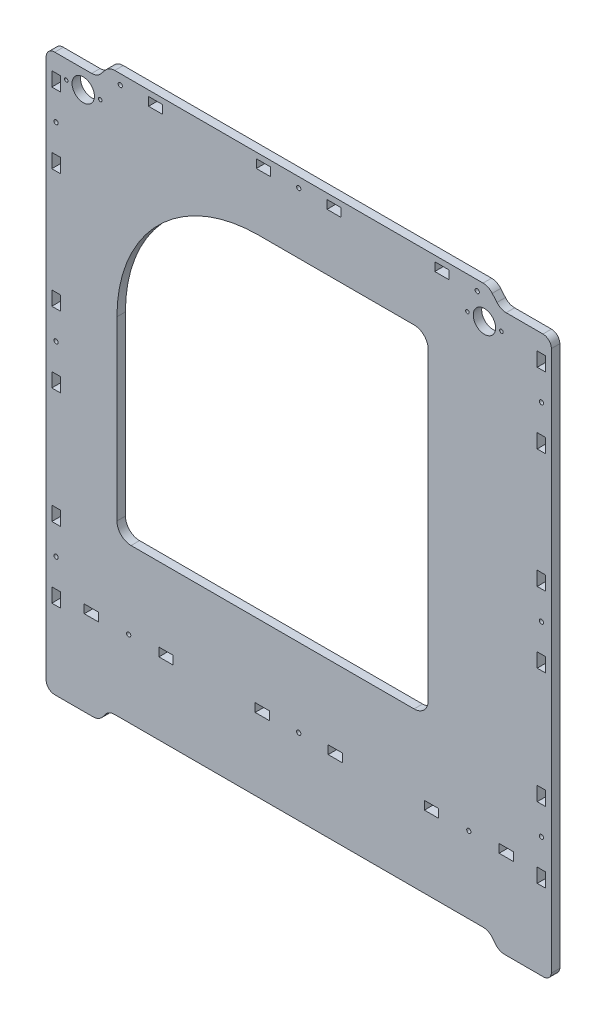
from build123d import *

# Parameters (mm, degrees)
SKETCH_1_R      = 1.5
SKETCH_1_R_2    = 7.9
SKETCH_1_R_3    = 1.25
SKETCH_1_W      = 6
SKETCH_1_H      = 10
SKETCH_1_W_2    = 10
SKETCH_1_H_2    = 6
EXTRUDE_1_DEPTH = 6


with BuildPart() as part:
    # Эскиз1 → Бобышка-Вытянуть1 (new body)
    with BuildSketch(Plane.XY):
        with BuildLine():
            Line((146.861398458, 191.532325026), (172.897783364, 191.532325026))
            ThreePointArc((172.897783364, 191.532325026), (177.076317747, 189.745999648), (178.804179186, 185.542952802))
            Line((178.804179186, 185.542952802), (178.804179186, -196.675834418))
            ThreePointArc((178.804179186, -196.675834418), (176.892140189, -200.429470569), (172.897783364, -201.767674974))
            Line((172.897783364, -201.767674974), (145.861398458, -201.767674974))
            ThreePointArc((145.861398458, -201.767674974), (142.269143233, -200.971291164), (139.350020692, -198.731369657))
            Line((139.350020692, -198.731369657), (137.054194639, -195.711716561))
            ThreePointArc((137.054194639, -195.711716561), (134.135072097, -193.471795054), (130.542816872, -192.675411244))
            Line((130.542816872, -192.675411244), (-129.747250144, -192.675411244))
            ThreePointArc((-129.747250144, -192.675411244), (-133.339505369, -193.471795054), (-136.258627911, -195.711716561))
            Line((-136.258627911, -195.711716561), (-138.554453964, -198.731369657))
            ThreePointArc((-138.554453964, -198.731369657), (-141.473576506, -200.971291164), (-145.06583173, -201.767674974))
            Line((-145.06583173, -201.767674974), (-172.102216636, -201.767674974))
            ThreePointArc((-172.102216636, -201.767674974), (-176.405497525, -200.043755719), (-178.195820814, -195.767674974))
            Line((-178.195820814, -195.767674974), (-178.195820814, 185.542952802))
            ThreePointArc((-178.195820814, 185.542952802), (-176.401714686, 189.812135315), (-172.102216636, 191.532325026))
            Line((-172.102216636, 191.532325026), (-146.06583173, 191.532325026))
            ThreePointArc((-146.06583173, 191.532325026), (-142.473576506, 192.328708836), (-139.554453964, 194.568630343))
            Line((-139.554453964, 194.568630343), (-136.258627911, 198.496442883))
            ThreePointArc((-136.258627911, 198.496442883), (-133.339449219, 200.73613298), (-129.747250144, 201.532325026))
            Line((-129.747250144, 201.532325026), (130.542816872, 201.532325026))
            ThreePointArc((130.542816872, 201.532325026), (134.135072097, 200.735941215), (137.054194639, 198.496019708))
            Line((137.054194639, 198.496019708), (140.350020692, 194.568207169))
            ThreePointArc((140.350020692, 194.568207169), (143.269199383, 192.328517071), (146.861398458, 191.532325026))
        make_face()
        with Locations((120.494179186, -138.767674974)):
            Circle(SKETCH_1_R, mode=Mode.SUBTRACT)
        with Locations((0.304179186, -138.767674974)):
            Circle(SKETCH_1_R, mode=Mode.SUBTRACT)
        with Locations((-119.885820814, -138.767674974)):
            Circle(SKETCH_1_R, mode=Mode.SUBTRACT)
        with Locations((-171.195820814, -116.737674974)):
            Circle(SKETCH_1_R, mode=Mode.SUBTRACT)
        with Locations((-171.195820814, 14.972325026)):
            Circle(SKETCH_1_R, mode=Mode.SUBTRACT)
        with Locations((171.804179186, 149.132325026)):
            Circle(SKETCH_1_R, mode=Mode.SUBTRACT)
        with Locations((126.444179186, 194.532325026)):
            Circle(SKETCH_1_R, mode=Mode.SUBTRACT)
        with Locations((-151.995820814, 178.532325026)):
            Circle(SKETCH_1_R_2, mode=Mode.SUBTRACT)
        with Locations((171.804179186, -116.737674974)):
            Circle(SKETCH_1_R, mode=Mode.SUBTRACT)
        with Locations((171.804179186, 14.972325026)):
            Circle(SKETCH_1_R, mode=Mode.SUBTRACT)
        with Locations((-171.195820814, 149.132325026)):
            Circle(SKETCH_1_R, mode=Mode.SUBTRACT)
        with Locations((-125.835820814, 194.532325026)):
            Circle(SKETCH_1_R, mode=Mode.SUBTRACT)
        with Locations((0.304179186, 194.54440539)):
            Circle(SKETCH_1_R, mode=Mode.SUBTRACT)
        with Locations((131.504179186, 178.532325026)):
            Circle(SKETCH_1_R_2, mode=Mode.SUBTRACT)
        with Locations((-139.995820814, 178.532325026)):
            Circle(SKETCH_1_R_3, mode=Mode.SUBTRACT)
        with Locations((-163.995820814, 178.532325026)):
            Circle(SKETCH_1_R_3, mode=Mode.SUBTRACT)
        with Locations((119.504179186, 178.532325026)):
            Circle(SKETCH_1_R_3, mode=Mode.SUBTRACT)
        with Locations((143.504179186, 178.532325026)):
            Circle(SKETCH_1_R_3, mode=Mode.SUBTRACT)
        with Locations((-171.195820814, 39.972325026)):
            Rectangle(SKETCH_1_W, SKETCH_1_H, mode=Mode.SUBTRACT)
        with Locations((171.804179186, 39.972325026)):
            Rectangle(SKETCH_1_W, SKETCH_1_H, mode=Mode.SUBTRACT)
        Polygon((174.804179186, 179.132325026), (174.804179186, 169.359038573), (174.804179186, 169.132325026), (168.804179186, 169.132325026), (168.804179186, 179.132325026), align=None, mode=Mode.SUBTRACT)
        Polygon((96.444179186, 197.532325026), (106.41988356, 197.532325026), (106.444179186, 197.514906712), (106.444179186, 191.332537312), (106.419882773, 191.532325026), (96.444179186, 191.532325026), align=None, mode=Mode.SUBTRACT)
        with Locations((26.094179186, -138.767674974)):
            Rectangle(SKETCH_1_W_2, SKETCH_1_H_2, mode=Mode.SUBTRACT)
        with Locations((-25.485820814, -138.767674974)):
            Rectangle(SKETCH_1_W_2, SKETCH_1_H_2, mode=Mode.SUBTRACT)
        with Locations((-171.195820814, 174.132325026)):
            Rectangle(SKETCH_1_W, SKETCH_1_H, mode=Mode.SUBTRACT)
        with Locations((94.094179186, -138.767674974)):
            Rectangle(SKETCH_1_W_2, SKETCH_1_H_2, mode=Mode.SUBTRACT)
        with Locations((146.894179186, -138.767674974)):
            Rectangle(SKETCH_1_W_2, SKETCH_1_H_2, mode=Mode.SUBTRACT)
        Polygon((-19.68524425, 191.532325026), (-29.685244433, 191.532325026), (-29.686393667, 197.532325026), (-19.686393484, 197.532325026), align=None, mode=Mode.SUBTRACT)
        with Locations((-171.195820814, 124.132325026)):
            Rectangle(SKETCH_1_W, SKETCH_1_H, mode=Mode.SUBTRACT)
        with Locations((-146.285820814, -138.767674974)):
            Rectangle(SKETCH_1_W_2, SKETCH_1_H_2, mode=Mode.SUBTRACT)
        with Locations((25.294179186, 194.532325026)):
            Rectangle(SKETCH_1_W_2, SKETCH_1_H_2, mode=Mode.SUBTRACT)
        with Locations((-171.195820814, -10.027674974)):
            Rectangle(SKETCH_1_W, SKETCH_1_H, mode=Mode.SUBTRACT)
        with Locations((-171.195820814, -91.757674974)):
            Rectangle(SKETCH_1_W, SKETCH_1_H, mode=Mode.SUBTRACT)
        with Locations((-171.195820814, -141.747674974)):
            Rectangle(SKETCH_1_W, SKETCH_1_H, mode=Mode.SUBTRACT)
        with Locations((-93.485820814, -138.767674974)):
            Rectangle(SKETCH_1_W_2, SKETCH_1_H_2, mode=Mode.SUBTRACT)
        with Locations((171.804179186, -10.027674974)):
            Rectangle(SKETCH_1_W, SKETCH_1_H, mode=Mode.SUBTRACT)
        with Locations((171.804179186, -91.757674974)):
            Rectangle(SKETCH_1_W, SKETCH_1_H, mode=Mode.SUBTRACT)
        with Locations((171.804179186, -141.747674974)):
            Rectangle(SKETCH_1_W, SKETCH_1_H, mode=Mode.SUBTRACT)
        with Locations((171.804179186, 124.132325026)):
            Rectangle(SKETCH_1_W, SKETCH_1_H, mode=Mode.SUBTRACT)
        Polygon((-95.835245647, 191.532325026), (-105.83524583, 191.532325026), (-105.836395064, 197.532325026), (-95.836394881, 197.532325026), align=None, mode=Mode.SUBTRACT)
        with BuildLine():
            Line((-128.195820814, -73.467674974), (-128.195820814, 51.532325026))
            ThreePointArc((-128.195820814, 51.532325026), (-98.906498933, 122.243003144), (-28.195820814, 151.532325026))
            Line((-28.195820814, 151.532325026), (81.804179186, 151.532325026))
            ThreePointArc((81.804179186, 151.532325026), (88.875246998, 148.603392838), (91.804179186, 141.532325026))
            Line((91.804179186, 141.532325026), (91.804179186, -73.467674974))
            ThreePointArc((91.804179186, -73.467674974), (88.875246998, -80.538742786), (81.804179186, -83.467674974))
            Line((81.804179186, -83.467674974), (-118.195820814, -83.467674974))
            ThreePointArc((-118.195820814, -83.467674974), (-125.266888626, -80.538742786), (-128.195820814, -73.467674974))
        make_face(mode=Mode.SUBTRACT)
    extrude(amount=EXTRUDE_1_DEPTH)


solid = part.part
